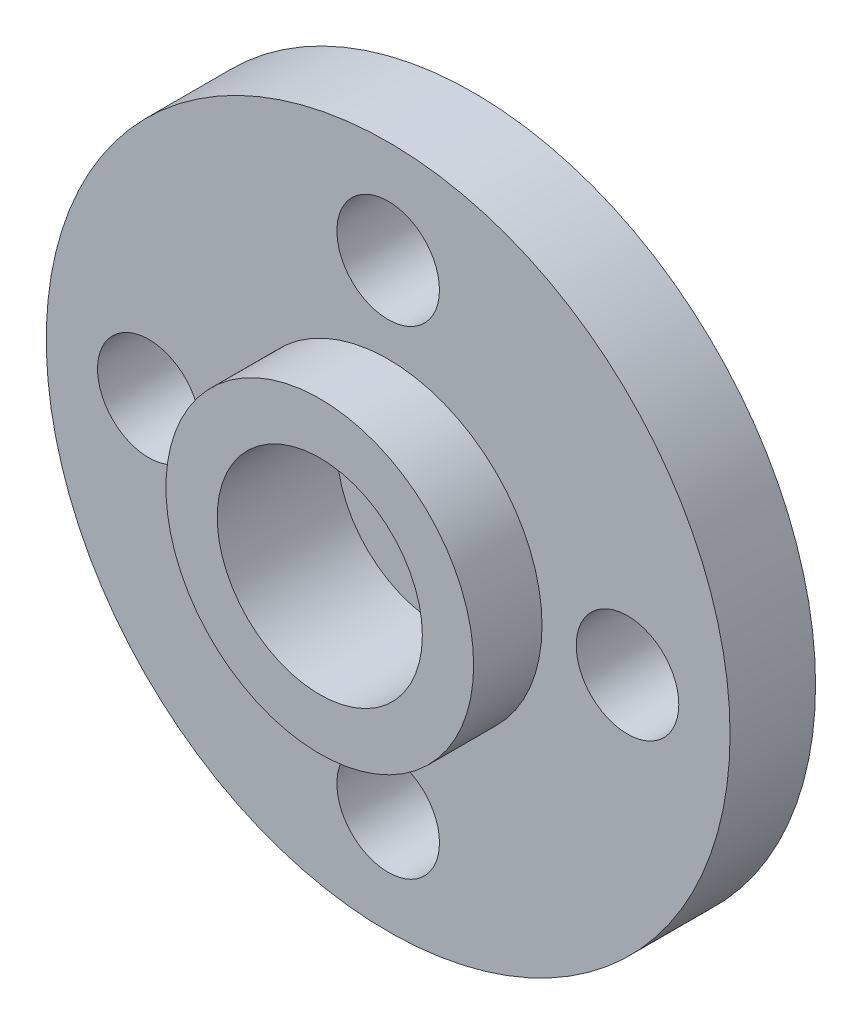
from build123d import *

# Parameters (mm, degrees)
SKETCH_1_R          = 10
SKETCH_1_R_2        = 1.5
EXTRUDE_1_DEPTH     = 2.5
SKETCH_2_R          = 4.5
EXTRUDE_2_DEPTH     = 2
SKETCH_3_R          = 3
CUT_EXTRUDE_1_DEPTH = 3.5
SKETCH_4_R          = 1.5
CUT_EXTRUDE_2_DEPTH = 3.5


with BuildPart() as part:
    # 草图1 → 凸台-拉伸1 (new body)
    with BuildSketch(Plane.XY):
        Circle(SKETCH_1_R)
        with Locations((0, 7)):
            Circle(SKETCH_1_R_2, mode=Mode.SUBTRACT)
        with Locations((0, -7)):
            Circle(SKETCH_1_R_2, mode=Mode.SUBTRACT)
        with Locations((-7, 0)):
            Circle(SKETCH_1_R_2, mode=Mode.SUBTRACT)
        with Locations((7, 0)):
            Circle(SKETCH_1_R_2, mode=Mode.SUBTRACT)
    extrude(amount=EXTRUDE_1_DEPTH)

    # 草图2 → 凸台-拉伸2 (add)
    with BuildSketch(Plane.XY.offset(2.5)):
        Circle(SKETCH_2_R)
    extrude(amount=EXTRUDE_2_DEPTH)

    # 草图3 → 切除-拉伸1 (cut)
    with BuildSketch(Plane.XY.offset(4.5)):
        Circle(SKETCH_3_R)
    extrude(amount=-CUT_EXTRUDE_1_DEPTH, mode=Mode.SUBTRACT)

    # 草图4 → 切除-拉伸2 (cut)
    with BuildSketch(Plane.XY.offset(1)):
        Circle(SKETCH_4_R)
    extrude(amount=-CUT_EXTRUDE_2_DEPTH, mode=Mode.SUBTRACT)


solid = part.part
